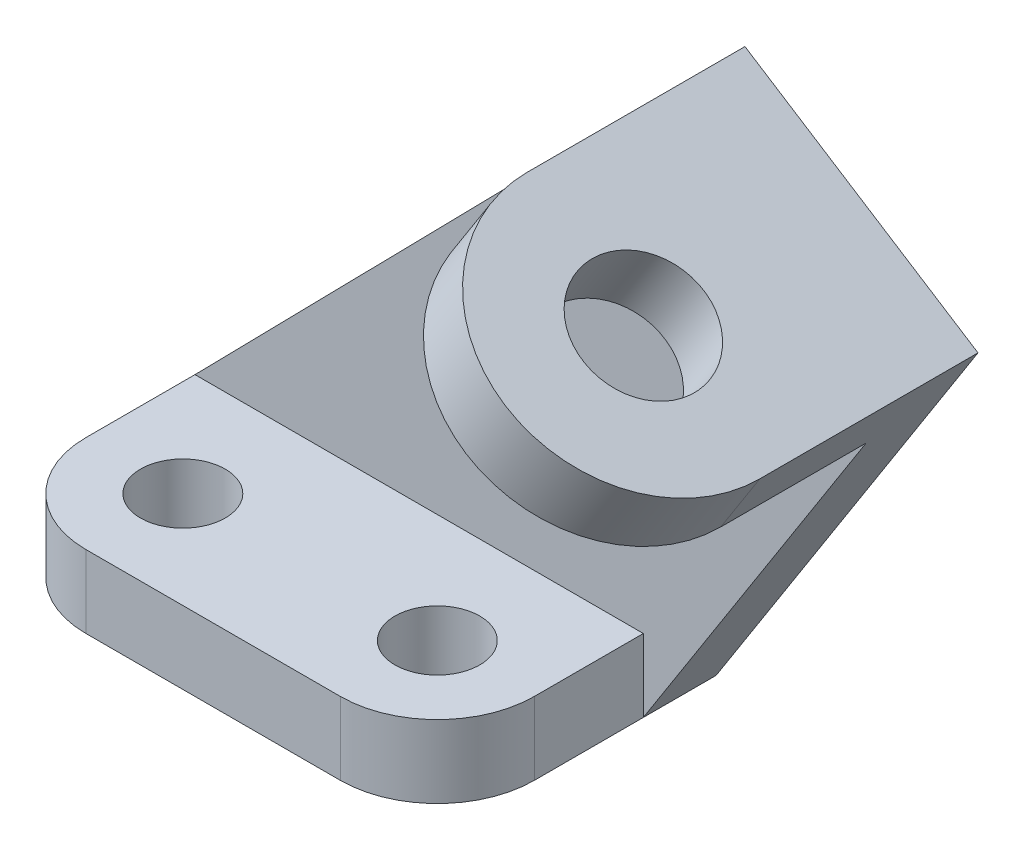
from build123d import *

# Parameters (mm, degrees)
SKETCH1_R           = 5.55625
BOSS_EXTRUDE1_DEPTH = 9.525
BOSS_EXTRUDE2_DEPTH = 9.525
SKETCH4_W           = 36.217026874
SKETCH4_H           = 9.525
BOSS_EXTRUDE3_DEPTH = 9.525


with BuildPart() as part:
    # Sketch1 → Boss-Extrude1 (new body)
    with BuildSketch(Plane(origin=(0, 0, 0), x_dir=(1, 0, 0), z_dir=(0, 1, 0))):
        with BuildLine():
            Line((29.36875, 0), (-29.36875, 0))
            Line((-29.36875, 0), (-29.36875, -23.8125))
            ThreePointArc((-29.36875, -23.8125), (-25.649006121, -32.792756121), (-16.66875, -36.5125))
            Line((-16.66875, -36.5125), (16.66875, -36.5125))
            ThreePointArc((16.66875, -36.5125), (25.649006121, -32.792756121), (29.36875, -23.8125))
            Line((29.36875, -23.8125), (29.36875, 0))
        make_face()
        with Locations((-16.66875, -23.8125)):
            Circle(SKETCH1_R, mode=Mode.SUBTRACT)
        with Locations((16.66875, -23.8125)):
            Circle(SKETCH1_R, mode=Mode.SUBTRACT)
    extrude(amount=BOSS_EXTRUDE1_DEPTH)

    # Sketch2 → Boss-Extrude2 (add)
    with BuildSketch(Plane(origin=(0, 0, 0), x_dir=(-1, 0, 0), z_dir=(0, 0, -1))):
        Polygon((-29.36875, 0), (-63.682676038, 53.756755119), (-33.154823962, 73.243244881), (29.36875, 9.525), (29.36875, 0), align=None)
    extrude(amount=-BOSS_EXTRUDE2_DEPTH)

    # Sketch4 → Boss-Extrude3 (add)
    with BuildSketch(Plane(origin=(42.816043465, 67.076310684, 0), x_dir=(0.842914361, -0.538047748, 0), z_dir=(0.538047748, 0.842914361, 0))):
        with Locations((6.646827712, -4.7625)):
            Rectangle(SKETCH4_W, SKETCH4_H)
        with BuildLine():
            Line((-1.290672288, -28.575), (-11.461685725, -28.575))
            ThreePointArc((-11.461685725, -28.575), (6.646827712, -46.683513437), (24.755341149, -28.575))
            Line((24.755341149, -28.575), (14.584327712, -28.575))
            ThreePointArc((14.584327712, -28.575), (6.646827712, -36.5125), (-1.290672288, -28.575))
        make_face()
        with BuildLine():
            Line((24.755341149, -9.525), (-11.461685725, -9.525))
            Line((-11.461685725, -9.525), (-11.461685725, -28.575))
            Line((-11.461685725, -28.575), (-1.290672288, -28.575))
            ThreePointArc((-1.290672288, -28.575), (6.646827712, -20.6375), (14.584327712, -28.575))
            Line((14.584327712, -28.575), (24.755341149, -28.575))
            Line((24.755341149, -28.575), (24.755341149, -9.525))
        make_face()
    extrude(amount=-BOSS_EXTRUDE3_DEPTH)


solid = part.part
